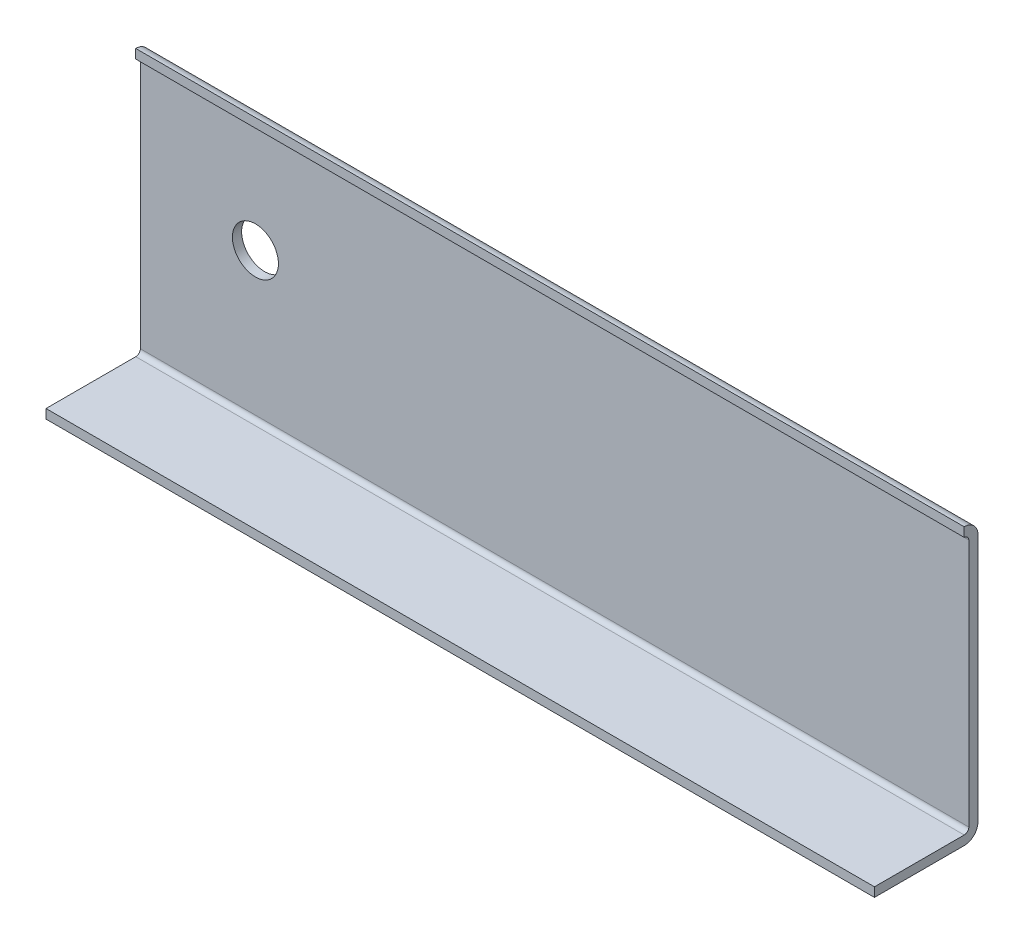
from build123d import *

# Parameters (mm, degrees)
EXTRUDE_1_DEPTH     = 180
SKETCH_2_W          = 180
SKETCH_2_H          = 17.5
CUT_EXTRUDE_1_DEPTH = 45
SKETCH_3_W          = 180
SKETCH_3_H          = 37
CUT_EXTRUDE_2_DEPTH = 25
SKETCH_4_R          = 5
CUT_EXTRUDE_3_DEPTH = 10


with BuildPart() as part:
    # Эскиз1 → Вытянуть-Тонкостенный1 (new body)
    with BuildSketch(Plane(origin=(0, 0, 0), x_dir=(0, 0, -1), z_dir=(1, 0, 0))):
        with BuildLine():
            Line((-2, 55), (-2, 1))
            ThreePointArc((-2, 1), (-1.121320344, -1.121320344), (1, -2))
            Line((1, -2), (35, -2))
            ThreePointArc((35, -2), (37.121320344, -1.121320344), (38, 1))
            Line((38, 1), (38, 55))
            ThreePointArc((38, 55), (37.121320344, 57.121320344), (35, 58))
            Line((35, 58), (1, 58))
            ThreePointArc((1, 58), (-1.121320344, 57.121320344), (-2, 55))
        make_face()
        with BuildLine():
            Line((0, 55), (0, 1))
            ThreePointArc((0, 1), (0.292893219, 0.292893219), (1, 0))
            Line((1, 0), (35, 0))
            ThreePointArc((35, 0), (35.707106781, 0.292893219), (36, 1))
            Line((36, 1), (36, 55))
            ThreePointArc((36, 55), (35.707106781, 55.707106781), (35, 56))
            Line((35, 56), (1, 56))
            ThreePointArc((1, 56), (0.292893219, 55.707106781), (0, 55))
        make_face(mode=Mode.SUBTRACT)
    extrude(amount=EXTRUDE_1_DEPTH)

    # Эскиз2 → Вырез-Вытянуть1 (cut)
    with BuildSketch(Plane.XZ.offset(2)):
        with Locations((90, -6.75)):
            Rectangle(SKETCH_2_W, SKETCH_2_H)
    extrude(amount=-CUT_EXTRUDE_1_DEPTH, mode=Mode.SUBTRACT)

    # Эскиз3 → Вырез-Вытянуть2 (cut)
    with BuildSketch(Plane(origin=(0, 58, 0), x_dir=(1, 0, 0), z_dir=(0, 1, 0))):
        with Locations((90, 16.5)):
            Rectangle(SKETCH_3_W, SKETCH_3_H)
    extrude(amount=-CUT_EXTRUDE_2_DEPTH, mode=Mode.SUBTRACT)

    # Эскиз4 → Вырез-Вытянуть3 (cut)
    with BuildSketch(Plane(origin=(0, 0, -38), x_dir=(-1, 0, 0), z_dir=(0, 0, -1))):
        with Locations((-25, 32)):
            Circle(SKETCH_4_R)
    extrude(amount=-CUT_EXTRUDE_3_DEPTH, mode=Mode.SUBTRACT)


solid = part.part
